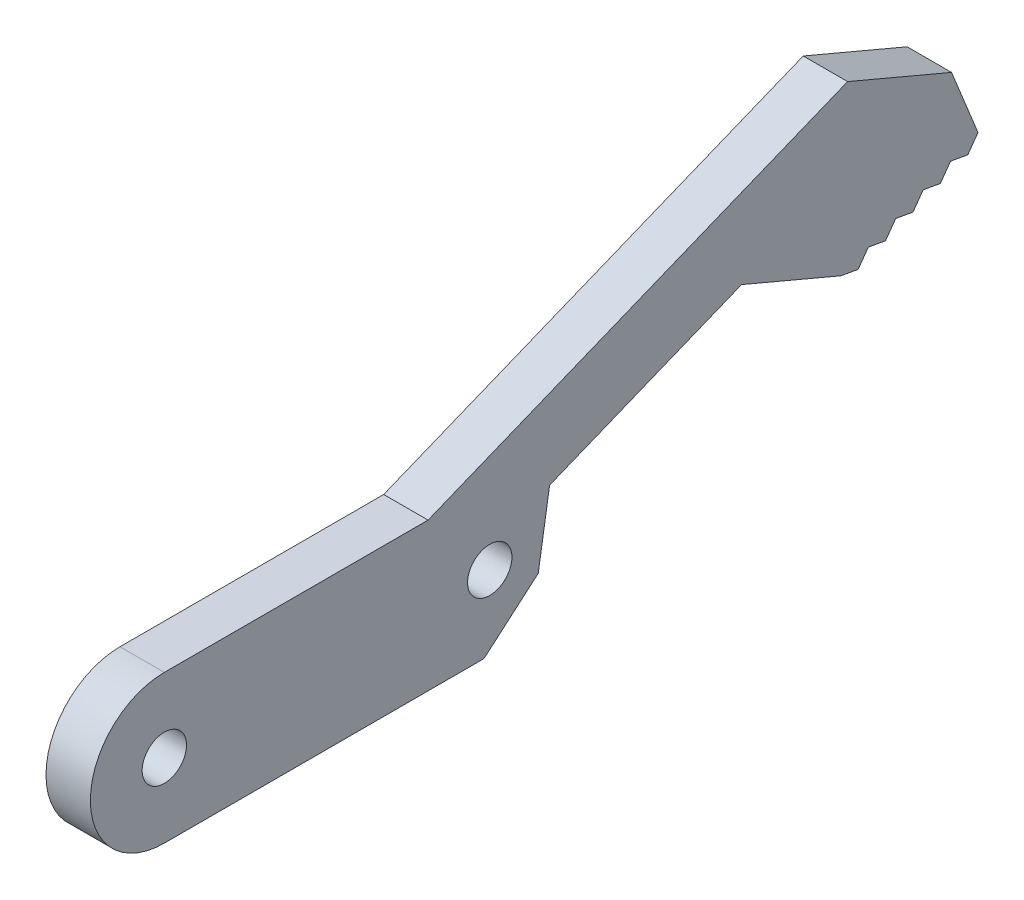
from build123d import *

# Parameters (mm, degrees)
SKETCH1_R           = 5
SKETCH1_R_2         = 1.5
BOSS_EXTRUDE1_DEPTH = 1.5
BOSS_EXTRUDE2_DEPTH = 3
CUT_EXTRUDE1_DEPTH  = 3
CUT_EXTRUDE2_DEPTH  = 3


with BuildPart() as part:
    # Sketch1 → Boss-Extrude1 (new body, symmetric)
    with BuildSketch(Plane(origin=(0, 0, 0), x_dir=(0, 0, -1), z_dir=(1, 0, 0))):
        with BuildLine():
            ThreePointArc((-6, 0), (-7.464466094, -3.535533906), (-11, -5))
            Line((-11, -5), (11, -5))
            ThreePointArc((11, -5), (6, 0), (11, 5))
            Line((11, 5), (-11, 5))
            ThreePointArc((-11, 5), (-7.464466094, 3.535533906), (-6, 0))
        make_face()
        with Locations((-11, 0)):
            Circle(SKETCH1_R)
        with Locations((-11, 0)):
            Circle(SKETCH1_R_2, mode=Mode.SUBTRACT)
        with Locations((11, 0)):
            Circle(SKETCH1_R)
        with Locations((11, 0)):
            Circle(SKETCH1_R_2, mode=Mode.SUBTRACT)
    extrude(amount=BOSS_EXTRUDE1_DEPTH, both=True)

    # Sketch2 → Boss-Extrude2 (add)
    with BuildSketch(Plane(origin=(1.5, 0, 0), x_dir=(0, 0, -1), z_dir=(1, 0, 0))):
        with BuildLine():
            Line((34.743210425, 5.347223248), (34.979783381, 4.763328363))
            Line((34.979783381, 4.763328363), (44.247956153, 8.518454657))
            Line((44.247956153, 8.518454657), (40.196320101, 18.518454657))
            Line((40.196320101, 18.518454657), (6.830898124, 5))
            Line((6.830898124, 5), (11, 5))
            ThreePointArc((11, 5), (13.272352736, 4.453808824), (15.048249866, 2.934565218))
            Line((15.048249866, 2.934565218), (28.023691746, 8.191742029))
            Line((28.023691746, 8.191742029), (34.743210425, 5.347223248))
        make_face()
    extrude(amount=-BOSS_EXTRUDE2_DEPTH)

    # Sketch3 → Cut-Extrude1 (cut)
    with BuildSketch(Plane(origin=(1.5, 0, 0), x_dir=(0, 0, -1), z_dir=(1, 0, 0))):
        Polygon((40.196320101, 18.518454657), (35.196320101, 16.492636631), (42.222138127, 13.518454657), align=None)
    extrude(amount=-CUT_EXTRUDE1_DEPTH, mode=Mode.SUBTRACT)

    # Sketch4 → Cut-Extrude2 (cut)
    with BuildSketch(Plane(origin=(1.5, 0, 0), x_dir=(0, 0, -1), z_dir=(1, 0, 0))):
        Polygon((36.596844979, 6.098248507), (35.906600658, 5.138840993), (37.760235213, 5.889866252), align=None)
        Polygon((35.906600658, 5.138840993), (34.743210425, 5.347223248), (34.979783381, 4.763328363), align=None)
        Polygon((38.450479533, 6.849273765), (37.760235213, 5.889866252), (39.613869767, 6.64089151), align=None)
        Polygon((40.304114087, 7.600299024), (39.613869767, 6.64089151), (41.467504321, 7.391916769), align=None)
        Polygon((42.157748642, 8.351324283), (41.467504321, 7.391916769), (43.321138875, 8.142942028), align=None)
        Polygon((44.011383196, 9.102349542), (43.321138875, 8.142942028), (44.247956153, 8.518454657), align=None)
        with BuildLine():
            ThreePointArc((11, -5), (15.453808824, -2.272352736), (15.048249866, 2.934565218))
            Line((15.048249866, 2.934565218), (14.279867332, -1.844052603))
            Line((14.279867332, -1.844052603), (10.610317492, -5))
            Line((10.610317492, -5), (11, -5))
        make_face()
    extrude(amount=-CUT_EXTRUDE2_DEPTH, mode=Mode.SUBTRACT)


solid = part.part
